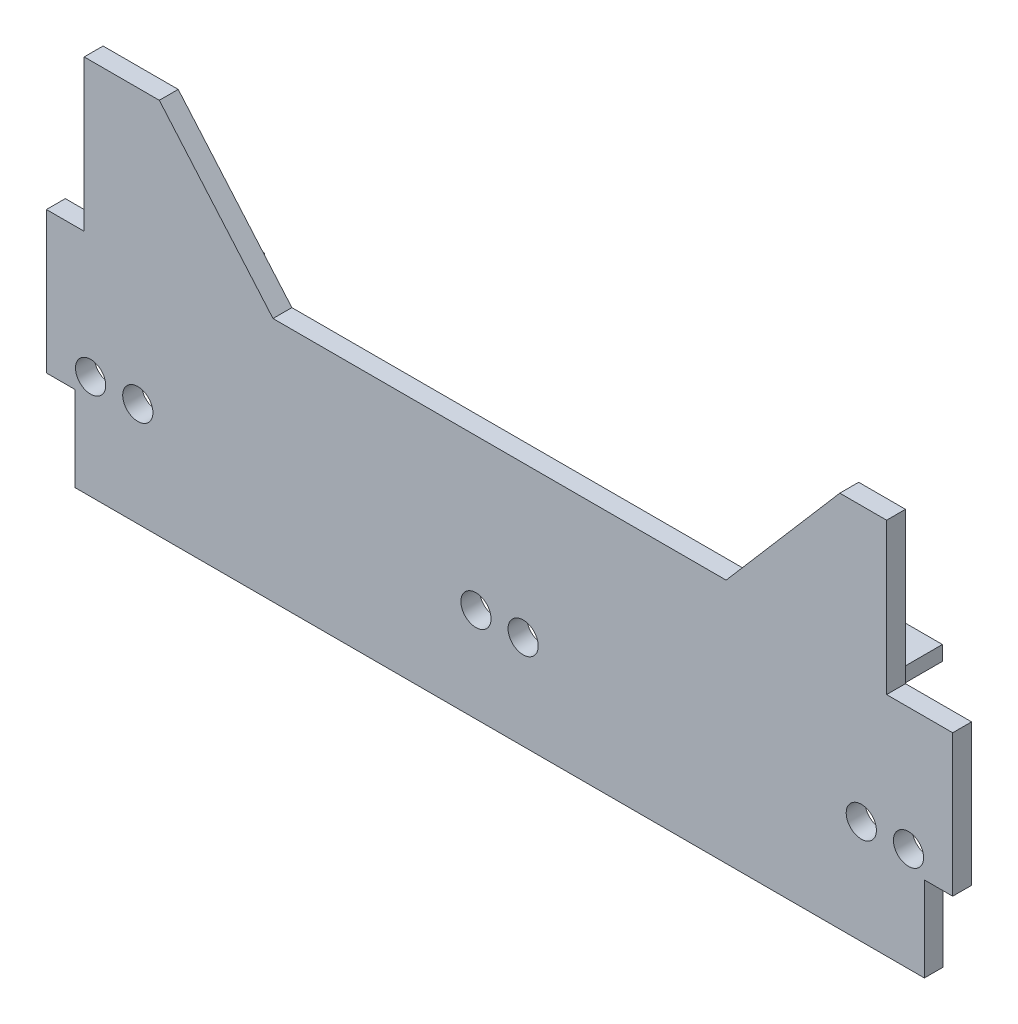
from build123d import *

# Parameters (mm, degrees)
SKETCH1_W           = 480
SKETCH1_H           = 200
BOSS_EXTRUDE1_DEPTH = 10
SKETCH2_W           = 30
SKETCH2_H           = 7.761380017
BOSS_EXTRUDE2_DEPTH = 30
SKETCH3_R           = 5
CUT_EXTRUDE1_DEPTH  = 30
SKETCH5_R           = 8
CUT_EXTRUDE2_DEPTH  = 30
SKETCH6_W           = 15
SKETCH6_H           = 45
SKETCH6_W_2         = 20
SKETCH6_H_2         = 80
SKETCH6_W_3         = 35
CUT_EXTRUDE3_DEPTH  = 10


with BuildPart() as part:
    # Sketch1 → Boss-Extrude1 (new body)
    with BuildSketch(Plane.XY):
        Rectangle(SKETCH1_W, SKETCH1_H)
    extrude(amount=BOSS_EXTRUDE1_DEPTH)

    # Sketch2 → Boss-Extrude2 (add)
    with BuildSketch(Plane(origin=(0, 0, 0), x_dir=(-1, 0, 0), z_dir=(0, 0, -1))):
        with Locations((-179.555, 13.880690009)):
            Rectangle(SKETCH2_W, SKETCH2_H)
        with Locations((179.555, 13.880690009)):
            Rectangle(SKETCH2_W, SKETCH2_H)
    extrude(amount=BOSS_EXTRUDE2_DEPTH)

    # Sketch3 → Cut-Extrude1 (cut)
    with BuildSketch(Plane(origin=(0, 17.761380017, 0), x_dir=(1, 0, 0), z_dir=(0, 1, 0))):
        with Locations((179.555, 15)):
            Circle(SKETCH3_R)
        with Locations((-179.555, 15)):
            Circle(SKETCH3_R)
    extrude(amount=-CUT_EXTRUDE1_DEPTH, mode=Mode.SUBTRACT)

    # Sketch5 → Cut-Extrude2 (cut)
    with BuildSketch(Plane.XY.offset(10)):
        with Locations((-12.5, -50)):
            Circle(SKETCH5_R)
        with Locations((-216.6, -45)):
            Circle(SKETCH5_R)
        with Locations((-191.6, -45)):
            Circle(SKETCH5_R)
        with Locations((12.5, -50)):
            Circle(SKETCH5_R)
        with Locations((191.6, -45)):
            Circle(SKETCH5_R)
        with Locations((216.6, -45)):
            Circle(SKETCH5_R)
        Polygon((140, 100), (90, 30), (-90, 30), (-140, 100), align=None)
    extrude(amount=-CUT_EXTRUDE2_DEPTH, mode=Mode.SUBTRACT)

    # Sketch6 → Cut-Extrude3 (cut)
    with BuildSketch(Plane(origin=(0, 0, 0), x_dir=(-1, 0, 0), z_dir=(0, 0, -1))):
        with Locations((-232.5, -77.5)):
            Rectangle(SKETCH6_W, SKETCH6_H)
        with Locations((232.5, -77.5)):
            Rectangle(SKETCH6_W, SKETCH6_H)
        with Locations((230, 60)):
            Rectangle(SKETCH6_W_2, SKETCH6_H_2)
        with Locations((-222.5, 60)):
            Rectangle(SKETCH6_W_3, SKETCH6_H_2)
        Polygon((140.207027179, 100), (180.207027179, 100), (120, 30), (90, 30), (114.970016322, 100), align=None)
        Polygon((-120, 30), (-90, 30), (-114.970016322, 100), (-140.207027179, 100), (-180.207027179, 100), align=None)
    extrude(amount=-CUT_EXTRUDE3_DEPTH, mode=Mode.SUBTRACT)


solid = part.part
